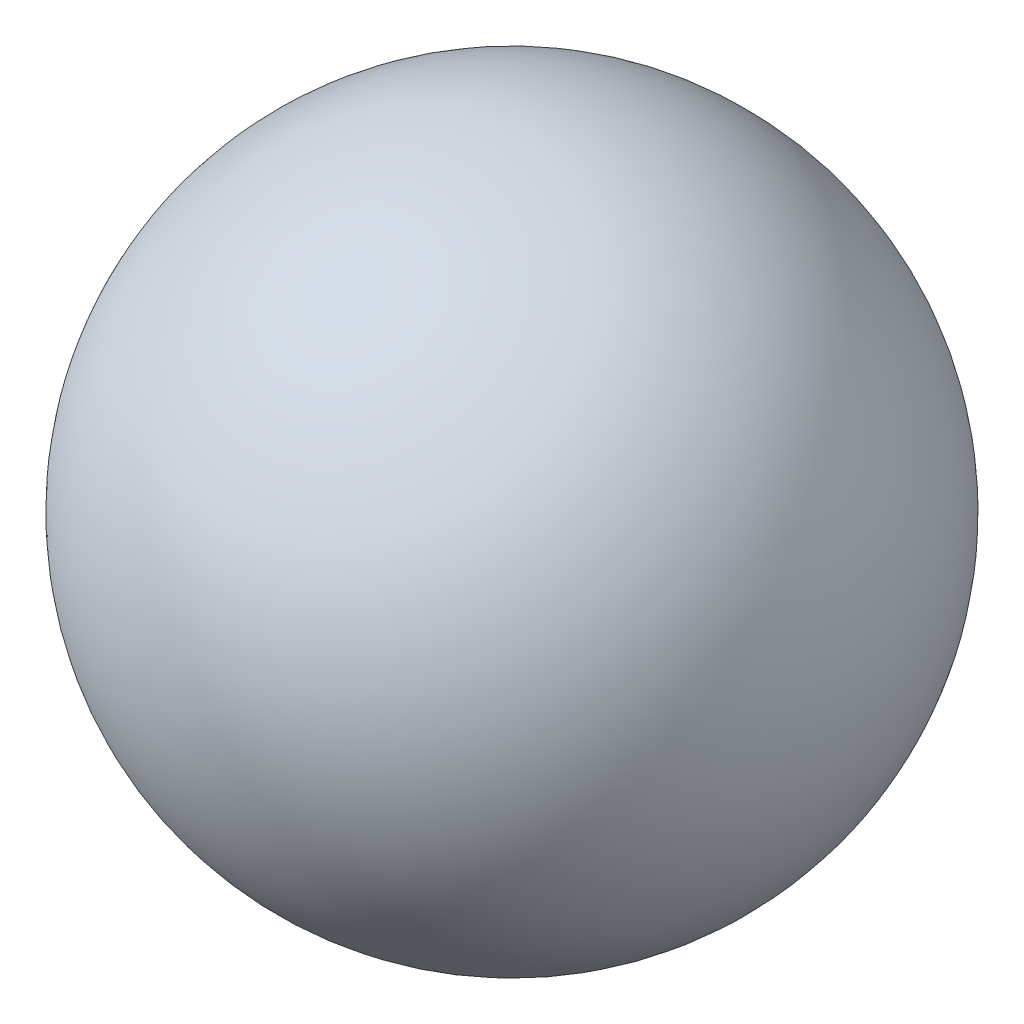
from build123d import *


with BuildPart() as part:
    # Skizze1 → Rotation1 (revolve)
    with BuildSketch(Plane.XY):
        with BuildLine():
            Line((5.4845, 7.35), (1.5155, 7.35))
            ThreePointArc((1.5155, 7.35), (3.5, 9.3345), (5.4845, 7.35))
        make_face()
    revolve(axis=Axis((5.4845, 7.35, 0), (-1, 0, 0)))


solid = part.part
